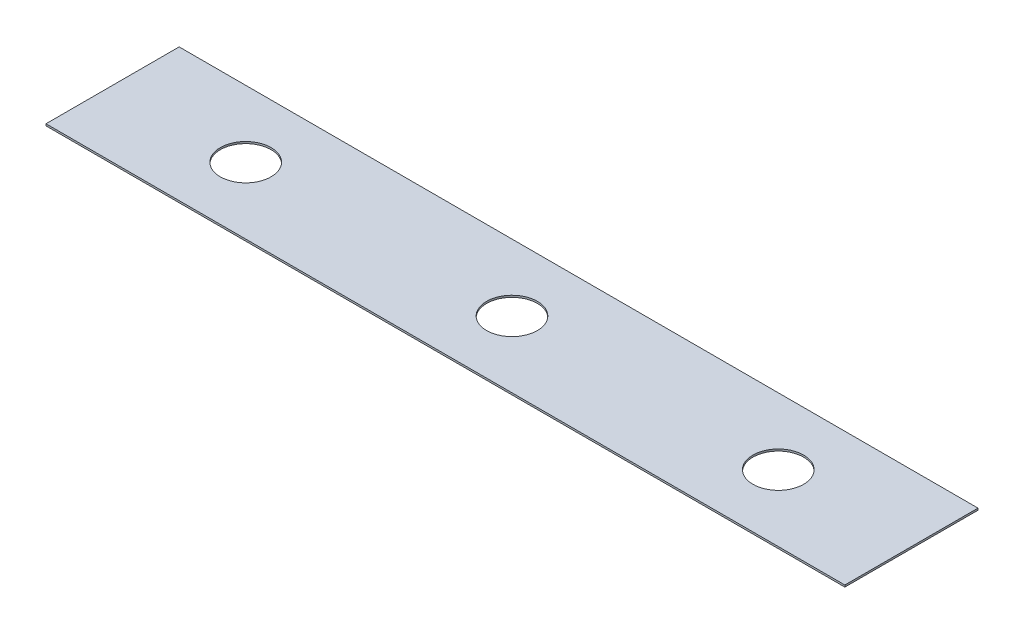
from build123d import *

# Parameters (mm, degrees)
SKETCH1_W           = 76.2
SKETCH1_H           = 12.7
BOSS_EXTRUDE1_DEPTH = 0.1778
SKETCH2_R           = 2.41935
CUT_EXTRUDE1_DEPTH  = 1.1778


with BuildPart() as part:
    # Sketch1 → Boss-Extrude1 (new body)
    with BuildSketch(Plane(origin=(0, 0, 0), x_dir=(1, 0, 0), z_dir=(0, 1, 0))):
        Rectangle(SKETCH1_W, SKETCH1_H)
    extrude(amount=BOSS_EXTRUDE1_DEPTH)

    # Sketch2 → Cut-Extrude1 (cut, through all)
    with BuildSketch(Plane(origin=(0, 0.1778, 0), x_dir=(1, 0, 0), z_dir=(0, 1, 0))):
        Circle(SKETCH2_R)
        with Locations((-25.4, 0)):
            Circle(SKETCH2_R)
        with Locations((25.4, 0)):
            Circle(SKETCH2_R)
    extrude(amount=-CUT_EXTRUDE1_DEPTH, mode=Mode.SUBTRACT)


solid = part.part
